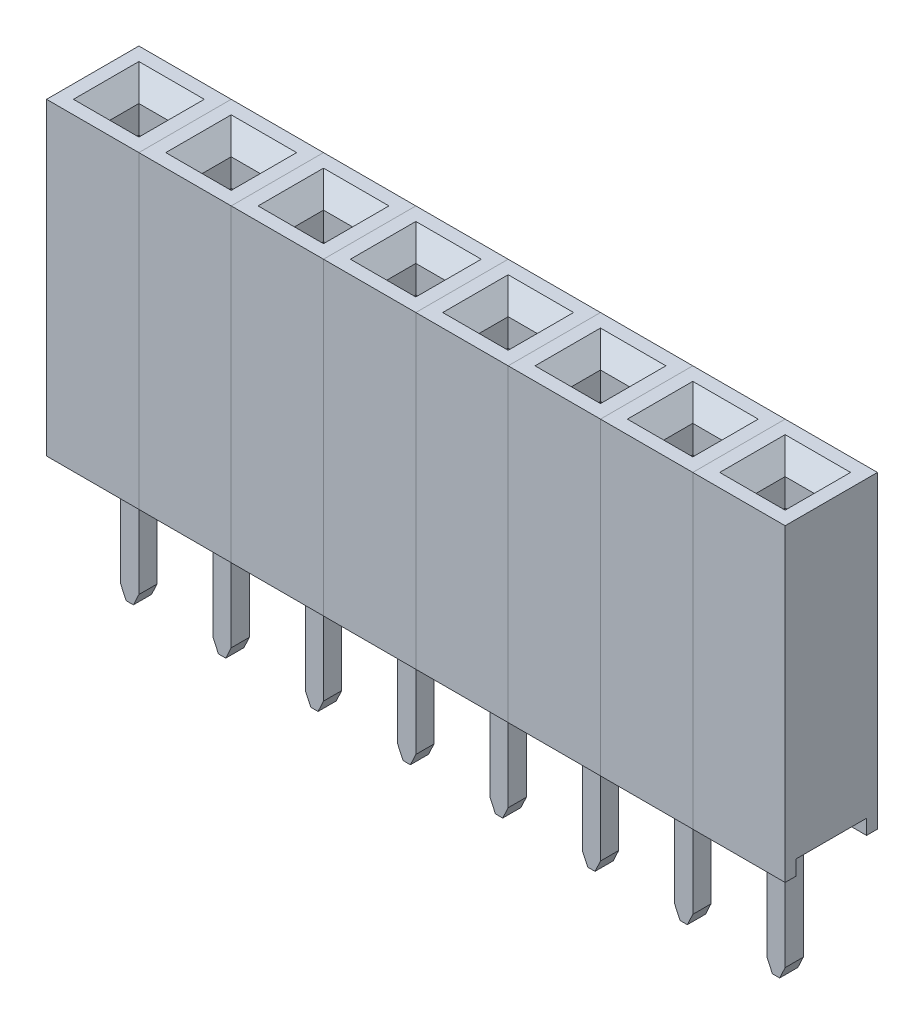
from build123d import *

# Parameters (mm, degrees)
SKETCH1_W               = 2.54
SKETCH1_H               = 8.5
BOSS_EXTRUDE1_DEPTH     = 1.27
SKETCH2_W               = 1.94
SKETCH2_H               = 0.410374384
CUT_EXTRUDE1_DEPTH      = 50
SKETCH4_W               = 0.8
SKETCH4_H               = 0.8
CUT_EXTRUDE2_DEPTH      = 1.5
CHAMFER1_SIZE           = 0.5
CUT_EXTRUDE3_DEPTH      = 3
CUT_EXTRUDE3_DEPTH_BACK = 3
SKETCH5_W               = 1.8
SKETCH5_H               = 1.8
BOSS_EXTRUDE4_DEPTH     = 0.85
BOSS_EXTRUDE5_DEPTH     = 0.25
LPATTERN1_COUNT         = 8
LPATTERN1_PITCH         = 2.54


with BuildPart() as part:
    # Sketch1 → Boss-Extrude1 (new, symmetric)
    with BuildSketch(Plane.XY):
        Rectangle(SKETCH1_W, SKETCH1_H)
    extrude(amount=BOSS_EXTRUDE1_DEPTH, both=True)

    # Sketch2 → Cut-Extrude1 (cut, symmetric)
    with BuildSketch(Plane(origin=(0, 0, 0), x_dir=(0, 0, -1), z_dir=(1, 0, 0))):
        with Locations((0, -4.044812808)):
            Rectangle(SKETCH2_W, SKETCH2_H)
    extrude(amount=CUT_EXTRUDE1_DEPTH, both=True, mode=Mode.SUBTRACT)

    # Sketch4 → Cut-Extrude2 (cut)
    with BuildSketch(Plane(origin=(0, 4.25, 0), x_dir=(1, 0, 0), z_dir=(0, 1, 0))):
        Rectangle(SKETCH4_W, SKETCH4_H)
    extrude(amount=-CUT_EXTRUDE2_DEPTH, mode=Mode.SUBTRACT)

    # Chamfer1
    chamfer1_edges = [part.edges().sort_by_distance(p)[0] for p in [
        (0, 4.25, -0.4),
        (-0.4, 4.25, 0),
        (0, 4.25, 0.4),
        (0.4, 4.25, 0),
    ]]
    chamfer(chamfer1_edges, length=CHAMFER1_SIZE)

    # Sketch5 → Cut-Extrude3 (cut, two sides: drawn at the far end of the back side and taken through both)
    with BuildSketch(Plane(origin=(0, 0, 0), x_dir=(1, 0, 0), z_dir=(0, 1, 0)).offset(-CUT_EXTRUDE3_DEPTH_BACK)):
        Rectangle(SKETCH5_W, SKETCH5_H)
    extrude(amount=CUT_EXTRUDE3_DEPTH + CUT_EXTRUDE3_DEPTH_BACK, mode=Mode.SUBTRACT)

    # Sketch9 → Boss-Extrude4 (add, symmetric)
    with BuildSketch(Plane.XY):
        with BuildLine():
            ThreePointArc((0.507505583, -1.97169351), (0.361743925, -2.312679398), (0, -2.394283131))
            ThreePointArc((0, -2.394283131), (-0.361743925, -2.312679398), (-0.507505583, -1.97169351))
            Line((-0.507505583, -1.97169351), (-0.280281264, 1.339289432))
            ThreePointArc((-0.280281264, 1.339289432), (-0.162585139, 1.576117793), (-0.413271806, 1.491878581))
            Line((-0.413271806, 1.491878581), (-0.602186386, -1.260876719))
            Line((-0.602186386, -1.260876719), (-0.852765845, -1.341648528))
            Line((-0.852765845, -1.341648528), (-0.852765845, -2.693306042))
            Line((-0.852765845, -2.693306042), (-0.280728289, -3.053320584))
            Line((-0.280728289, -3.053320584), (0.280728289, -3.053320584))
            Line((0.280728289, -3.053320584), (0.852765845, -2.693306042))
            Line((0.852765845, -2.693306042), (0.852765845, -1.341648528))
            Line((0.852765845, -1.341648528), (0.602186386, -1.260876719))
            Line((0.602186386, -1.260876719), (0.413271806, 1.491878581))
            ThreePointArc((0.413271806, 1.491878581), (0.162585139, 1.576117793), (0.280281264, 1.339289432))
            Line((0.280281264, 1.339289432), (0.507505583, -1.97169351))
        make_face()
    extrude(amount=BOSS_EXTRUDE4_DEPTH, both=True)

    # Sketch9_3 → Boss-Extrude5 (add, symmetric)
    with BuildSketch(Plane.XY):
        Polygon((0.25, -7.299491593), (0.25, -3.053320584), (-0.25, -3.053320584), (-0.25, -7.299491593), (-0.1, -7.621167632), (0.1, -7.621167632), align=None)
    extrude(amount=BOSS_EXTRUDE5_DEPTH, both=True)


with BuildPart() as lpattern1_1:
    # LPattern1: pattern copy
    add(part.part.moved(Location(Vector(-1, 0, 0) * (1 * LPATTERN1_PITCH))))


with BuildPart() as lpattern1_2:
    # LPattern1: pattern copy
    add(part.part.moved(Location(Vector(-1, 0, 0) * (2 * LPATTERN1_PITCH))))


with BuildPart() as lpattern1_3:
    # LPattern1: pattern copy
    add(part.part.moved(Location(Vector(-1, 0, 0) * (3 * LPATTERN1_PITCH))))


with BuildPart() as lpattern1_4:
    # LPattern1: pattern copy
    add(part.part.moved(Location(Vector(-1, 0, 0) * (4 * LPATTERN1_PITCH))))


with BuildPart() as lpattern1_5:
    # LPattern1: pattern copy
    add(part.part.moved(Location(Vector(-1, 0, 0) * (5 * LPATTERN1_PITCH))))


with BuildPart() as lpattern1_6:
    # LPattern1: pattern copy
    add(part.part.moved(Location(Vector(-1, 0, 0) * (6 * LPATTERN1_PITCH))))


with BuildPart() as lpattern1_7:
    # LPattern1: pattern copy
    add(part.part.moved(Location(Vector(-1, 0, 0) * (7 * LPATTERN1_PITCH))))


solid = Compound([part.part, lpattern1_1.part, lpattern1_2.part, lpattern1_3.part, lpattern1_4.part, lpattern1_5.part, lpattern1_6.part, lpattern1_7.part])
